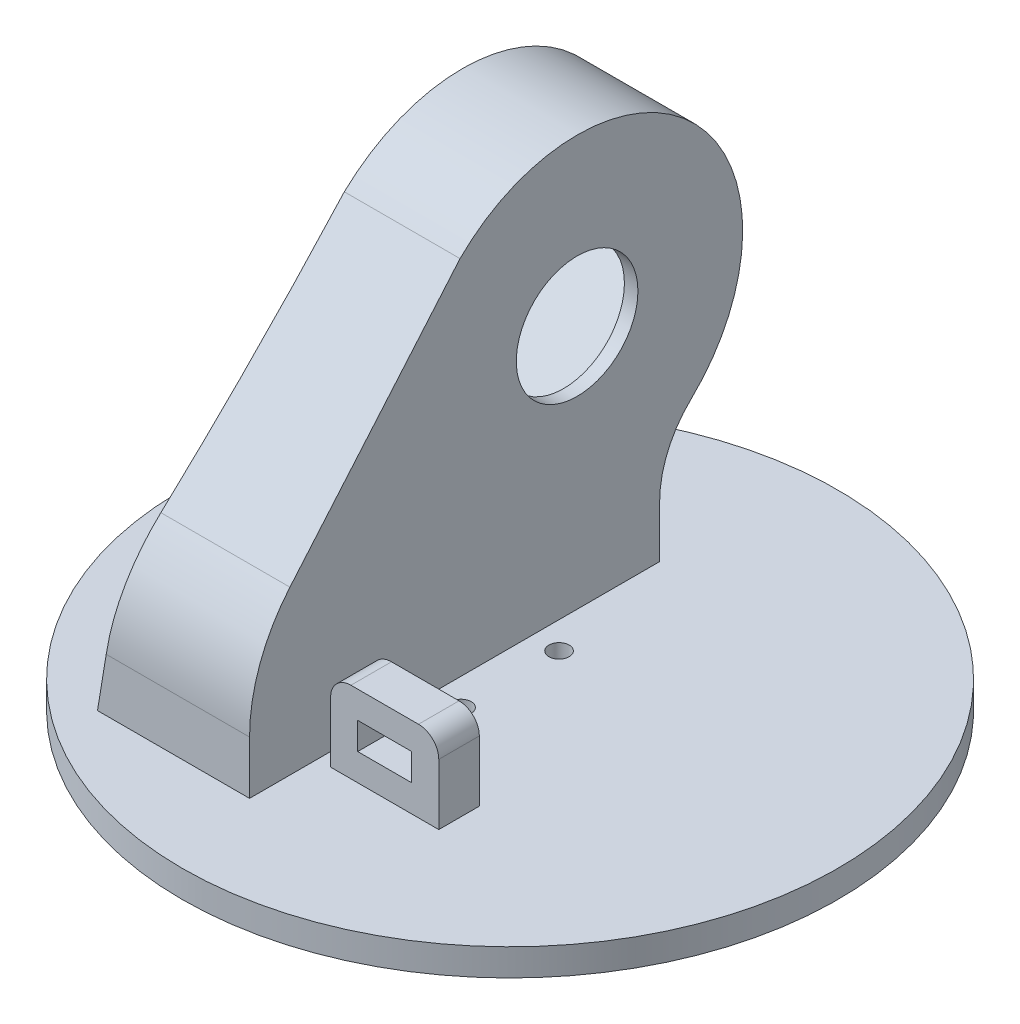
from build123d import *

# Parameters (mm, degrees)
SKETCH2_R                = 48.5
BOSS_EXTRUDE1_DEPTH      = 4
SKETCH4_R                = 1.5
CUT_EXTRUDE2_DEPTH       = 5
SKETCH5_R                = 3.75
CUT_EXTRUDE3_DEPTH       = 1.5
BOSS_EXTRUDE2_DEPTH      = 14
CUT_EXTRUDE5_REACH       = 44.5
SKETCH9_R                = 1.3
CUT_EXTRUDE6_DEPTH       = 7.5
CUT_EXTRUDE9_REACH       = 46.5
SKETCH11_R               = 9
BOSS_EXTRUDE7_DEPTH      = 9
BOSS_EXTRUDE7_DEPTH_BACK = 14
BOSS_EXTRUDE10_DEPTH     = 9
SKETCH27_W               = 16
SKETCH27_H               = 6
BOSS_EXTRUDE11_DEPTH     = 12
FILLET6_R                = 3
CUT_EXTRUDE16_REACH      = 75.05
SKETCH28_W               = 8
SKETCH28_H               = 4
CUT_EXTRUDE17_DEPTH      = 49.5
CUT_EXTRUDE17_DEPTH_BACK = 49.5


with BuildPart() as part:
    # Sketch2 → Boss-Extrude1 (new body)
    with BuildSketch(Plane(origin=(0, 0, 0), x_dir=(1, 0, 0), z_dir=(0, 1, 0))):
        Circle(SKETCH2_R)
    extrude(amount=BOSS_EXTRUDE1_DEPTH)

    # Sketch4 → Cut-Extrude2 (cut, through all)
    with BuildSketch(Plane.XZ):
        with Locations((0, 7.25)):
            Circle(SKETCH4_R)
        with Locations((0, -7.25)):
            Circle(SKETCH4_R)
    extrude(amount=-CUT_EXTRUDE2_DEPTH, mode=Mode.SUBTRACT)

    # Sketch5 → Cut-Extrude3 (cut)
    with BuildSketch(Plane.XZ):
        Circle(SKETCH5_R)
    extrude(amount=-CUT_EXTRUDE3_DEPTH, mode=Mode.SUBTRACT)

    # Sketch7 → Boss-Extrude2 (add)
    with BuildSketch(Plane(origin=(-4, 0, 0), x_dir=(0, 0, -1), z_dir=(1, 0, 0))):
        with BuildLine():
            Line((23.129947874, 4), (23.129947874, 11.644549616))
            ThreePointArc((23.129947874, 11.644549616), (24.589048403, 18.743749901), (28.729797284, 24.692011643))
            ThreePointArc((28.729797284, 24.692011643), (29.313383054, 55.284736897), (-1.284289494, 55.479275971))
            Line((-1.284289494, 55.479275971), (-27.227315747, 29.536249718))
            ThreePointArc((-27.227315747, 29.536249718), (-32.64663453, 21.425665997), (-34.549646217, 11.858580188))
            Line((-34.549646217, 11.858580188), (-34.549646217, 4))
            Line((-34.549646217, 4), (23.129947874, 4))
        make_face()
    extrude(amount=-BOSS_EXTRUDE2_DEPTH)

    # Sketch8 → Cut-Extrude5 (cut, up to next)
    with BuildSketch(Plane(origin=(-6, 0, 0), x_dir=(0, 0, -1), z_dir=(1, 0, 0)), mode=Mode.PRIVATE) as cut_extrude5_sk1:
        Polygon((-15.249648422, 25.957567857), (13.741729607, 54.948945886), (28.590972012, 40.099703481), (-0.400406017, 11.108325452), align=None)
    cut_extrude5_tool1 = extrude(cut_extrude5_sk1.sketch, amount=-CUT_EXTRUDE5_REACH, mode=Mode.PRIVATE) & part.part
    add(cut_extrude5_tool1.solids().sort_by_distance((-6, 33.028636, -6.670662))[0], mode=Mode.SUBTRACT)

    # Sketch9 → Cut-Extrude6 (cut)
    with BuildSketch(Plane.ZY.offset(18)):
        with Locations((-20.105690637, 53.534732323)):
            Circle(SKETCH9_R)
        with Locations((-27.176758449, 46.463664511)):
            Circle(SKETCH9_R)
        with Locations((6.764367048, 12.522539014)):
            Circle(SKETCH9_R)
        with Locations((13.83543486, 19.593606826)):
            Circle(SKETCH9_R)
    extrude(amount=-CUT_EXTRUDE6_DEPTH, mode=Mode.SUBTRACT)

    # Sketch11 → Cut-Extrude9 (cut, up to next)
    with BuildSketch(Plane(origin=(-4, 0, 0), x_dir=(0, 0, -1), z_dir=(1, 0, 0)), mode=Mode.PRIVATE) as cut_extrude9_sk1:
        with Locations((13.918506302, 40.276480176)):
            Circle(SKETCH11_R)
    cut_extrude9_tool1 = extrude(cut_extrude9_sk1.sketch, amount=-CUT_EXTRUDE9_REACH, mode=Mode.PRIVATE) & part.part
    add(cut_extrude9_tool1.solids().sort_by_distance((-4, 40.27648, -13.918506))[0], mode=Mode.SUBTRACT)

    # Sketch17 → Boss-Extrude7 (add, two sides)
    with BuildSketch(Plane.ZY.offset(18)) as boss_extrude7_sk:
        with BuildLine():
            ThreePointArc((34.549646217, 11.858580188), (33.008342843, 20.500891953), (28.574482006, 28.077569775))
            ThreePointArc((28.574482006, 28.077569775), (27.915386359, 28.820289685), (27.227315747, 29.536249718))
            Line((27.227315747, 29.536249718), (1.284289494, 55.479275971))
            Line((1.284289494, 55.479275971), (26.295003593, 26.127182305))
            ThreePointArc((26.295003593, 26.127182305), (30.194232218, 19.461281607), (31.549646217, 11.858580188))
            Line((31.549646217, 11.858580188), (31.549646217, 4))
            Line((31.549646217, 4), (34.549646217, 4))
            Line((34.549646217, 4), (34.549646217, 11.858580188))
        make_face()
        with BuildLine():
            Line((28.574482006, 28.077569775), (3.405609837, 57.600596315))
            ThreePointArc((3.405609837, 57.600596315), (-31.461505391, 57.378912253), (-30.796489049, 22.517434639))
            ThreePointArc((-30.796489049, 22.517434639), (-27.345864981, 17.560549854), (-26.129947874, 11.644549616))
            Line((-26.129947874, 11.644549616), (-26.129947874, 4))
            Line((-26.129947874, 4), (-23.129947874, 4))
            Line((-23.129947874, 4), (-23.129947874, 11.644549616))
            ThreePointArc((-23.129947874, 11.644549616), (-24.589048403, 18.743749901), (-28.729797284, 24.692011643))
            ThreePointArc((-28.729797284, 24.692011643), (-29.313383054, 55.284736897), (1.284289494, 55.479275971))
            Line((1.284289494, 55.479275971), (27.227315747, 29.536249718))
            ThreePointArc((27.227315747, 29.536249718), (27.915386359, 28.820289685), (28.574482006, 28.077569775))
        make_face()
    extrude(amount=BOSS_EXTRUDE7_DEPTH)
    extrude(boss_extrude7_sk.sketch, amount=-BOSS_EXTRUDE7_DEPTH_BACK)

    # Sketch25 → Boss-Extrude10 (add)
    with BuildSketch(Plane.ZY.offset(18)):
        with BuildLine():
            ThreePointArc((-28.729797284, 24.692011643), (-24.589048403, 18.743749901), (-23.129947874, 11.644549616))
            Line((-23.129947874, 11.644549616), (-23.129947874, 4))
            Line((-23.129947874, 4), (-15.129947874, 4))
            add(Edge.make_bspline(
                [(-28.729797284, 24.692011643), (-21.954867515, 18.253200081), (-19.09405247, 12.798017691), (-15.129947874, 4)],
                knots=[0, 0, 0, 0, 1, 1, 1, 1], degree=3))
        make_face()
        with BuildLine():
            add(Edge.make_bspline(
                [(11.751619577, 43.19501844), (26.551255916, 25.8264495), (25.549646217, 4)],
                knots=[0, 0, 0, 1, 1, 1], degree=2))
            Line((25.549646217, 4), (31.549646217, 4))
            Line((31.549646217, 4), (31.549646217, 11.858580188))
            ThreePointArc((31.549646217, 11.858580188), (30.194232218, 19.461281607), (26.295003593, 26.127182305))
            Line((26.295003593, 26.127182305), (11.751619577, 43.19501844))
        make_face()
    extrude(amount=BOSS_EXTRUDE10_DEPTH)

    # Sketch27 → Boss-Extrude11 (add)
    with BuildSketch(Plane(origin=(0, 4, 0), x_dir=(1, 0, 0), z_dir=(0, 1, 0))):
        with Locations((6, -21.549646217)):
            Rectangle(SKETCH27_W, SKETCH27_H)
    extrude(amount=BOSS_EXTRUDE11_DEPTH)

    # Fillet6
    fillet6_edges = [part.edges().sort_by_distance(p)[0] for p in [
        (-2, 16, 21.549646217),
        (14, 16, 21.549646217),
    ]]
    fillet(fillet6_edges, radius=FILLET6_R)

    # Sketch28 → Cut-Extrude16 (cut, up to next)
    with BuildSketch(Plane.XY.offset(24.549646217), mode=Mode.PRIVATE) as cut_extrude16_sk1:
        with Locations((6, 10)):
            Rectangle(SKETCH28_W, SKETCH28_H)
    cut_extrude16_tool1 = extrude(cut_extrude16_sk1.sketch, amount=-CUT_EXTRUDE16_REACH, mode=Mode.PRIVATE) & part.part
    add(cut_extrude16_tool1.solids().sort_by_distance((6, 10, 24.549646))[0], mode=Mode.SUBTRACT)

    # Sketch29 → Cut-Extrude17 (cut, two sides)
    with BuildSketch(Plane.XY) as cut_extrude17_sk:
        with BuildLine():
            Line((-21, 64.776480176), (-27, 64.776480176))
            Line((-27, 64.776480176), (-27, 4))
            Line((-27, 4), (-26.5, 4))
            add(Edge.make_bspline(
                [(-21, 64.776480176), (-21.220459696, 34.140901434), (-26.5, 4)],
                knots=[0, 0, 0, 1, 1, 1], degree=2))
        make_face()
    extrude(amount=CUT_EXTRUDE17_DEPTH, mode=Mode.SUBTRACT)
    extrude(cut_extrude17_sk.sketch, amount=-CUT_EXTRUDE17_DEPTH_BACK, mode=Mode.SUBTRACT)


solid = part.part
